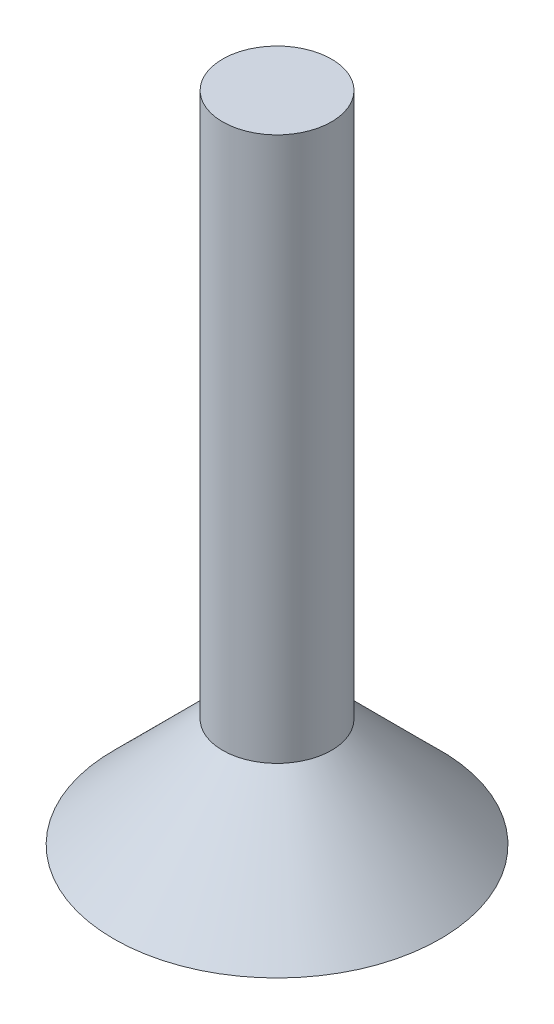
from build123d import *


with BuildPart() as part:
    # Эскиз1 → Повернуть1 (revolve)
    with BuildSketch(Plane.XY):
        Polygon((0, 15), (1.25, 15), (1.25, 2.5), (3.75, 0), (0, 0), align=None)
    revolve(axis=Axis((0, 49.838039672, 0), (0, -1, 0)))


solid = part.part
